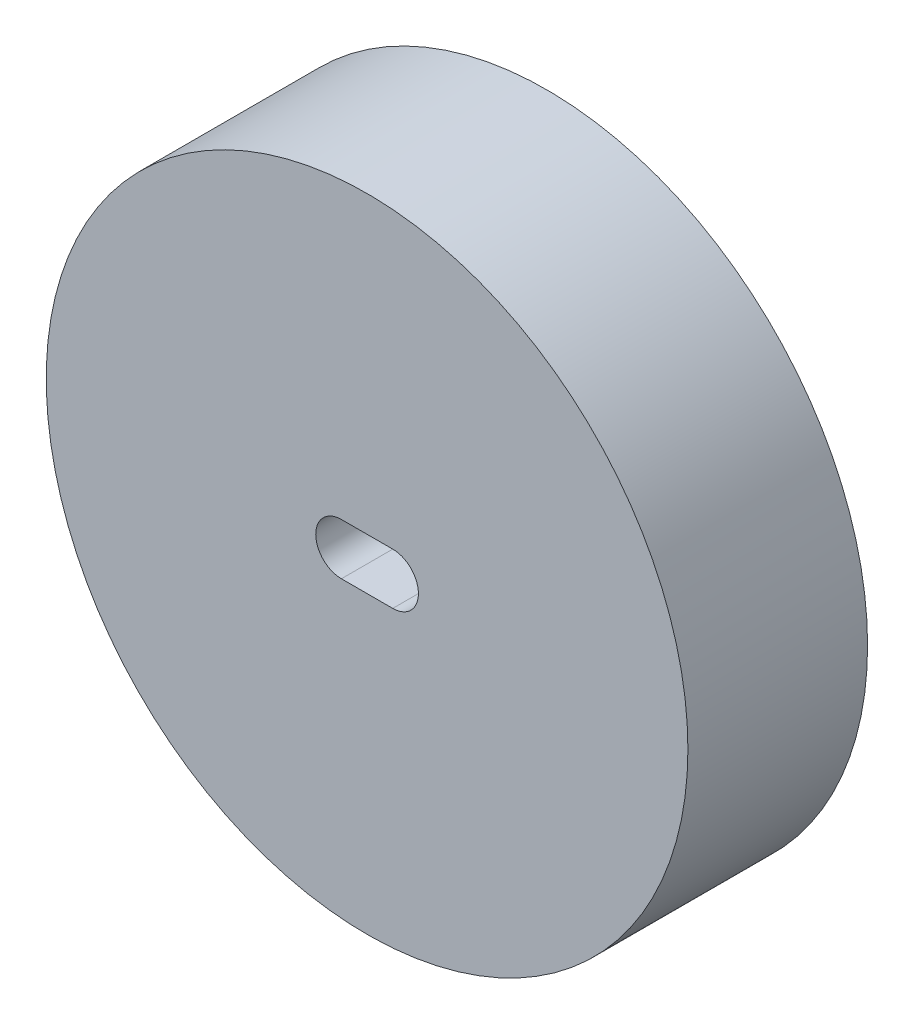
from build123d import *

# Parameters (mm, degrees)
SKETCH1_R           = 12.5
BOSS_EXTRUDE1_DEPTH = 3.5


with BuildPart() as part:
    # Sketch1 → Boss-Extrude1 (new body, symmetric)
    with BuildSketch(Plane.XY):
        Circle(SKETCH1_R)
        with BuildLine():
            Line((1, -1), (-1, -1))
            ThreePointArc((-1, -1), (-2, 0), (-1, 1))
            Line((-1, 1), (1, 1))
            ThreePointArc((1, 1), (2, 0), (1, -1))
        make_face(mode=Mode.SUBTRACT)
    extrude(amount=BOSS_EXTRUDE1_DEPTH, both=True)


solid = part.part
